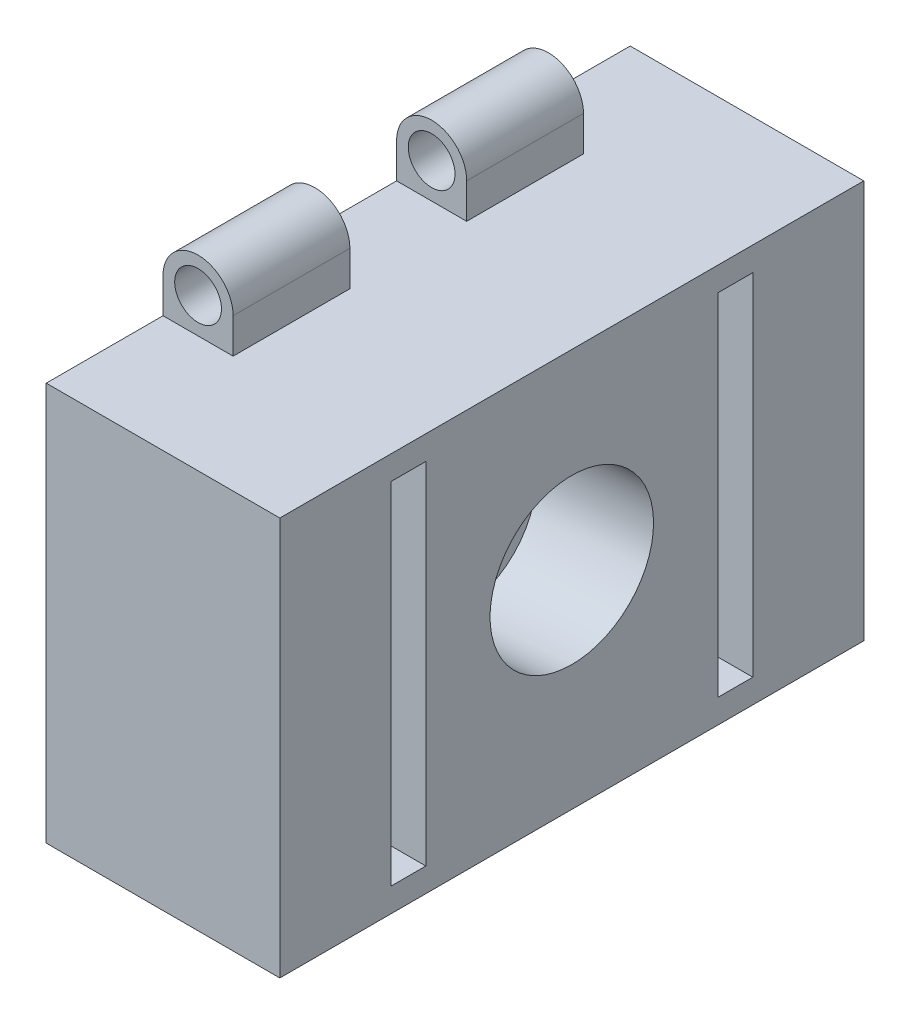
from build123d import *

# Parameters (mm, degrees)
SKETCH1_W                      = 50
SKETCH1_H                      = 34.11
BOSS_EXTRUDE1_DEPTH            = 20
SKETCH3_R                      = 2
BOSS_EXTRUDE2_DEPTH            = 10
LPATTERN1_COUNT                = 2
LPATTERN1_PITCH                = 20
MIRROR1_COPY_1_SKETCH_R        = 2
MIRROR1_COPY_1_DEPTH           = 10
SKETCH5_R                      = 7
CUT_EXTRUDE1_DEPTH             = 10
CUT_EXTRUDE1_DIRECTION_2_REACH = 3.559
SKETCH6_W                      = 3
SKETCH6_H                      = 30
CUT_EXTRUDE2_DEPTH             = 10


with BuildPart() as part:
    # Sketch1 → Boss-Extrude1 (new body)
    with BuildSketch(Plane(origin=(0, 0, 0), x_dir=(0, 0, -1), z_dir=(1, 0, 0))):
        with Locations((25, 17.055)):
            Rectangle(SKETCH1_W, SKETCH1_H)
    extrude(amount=BOSS_EXTRUDE1_DEPTH)

    # Sketch3 → Boss-Extrude2 (add)
    with BuildSketch(Plane.XY.offset(-10)):
        with BuildLine():
            Line((0, 34.11), (0, 37.11))
            ThreePointArc((0, 37.11), (3, 40.11), (6, 37.11))
            Line((6, 37.11), (6, 34.11))
            Line((6, 34.11), (3, 34.11))
            Line((3, 34.11), (0, 34.11))
        make_face()
        with Locations((3, 37.11)):
            Circle(SKETCH3_R, mode=Mode.SUBTRACT)
    boss_extrude2 = extrude(amount=-BOSS_EXTRUDE2_DEPTH)

    # LPattern1: Boss-Extrude2 ×2
    with Locations(*[(0, 0, -i * LPATTERN1_PITCH) for i in range(1, LPATTERN1_COUNT)]):
        add(boss_extrude2)

    # Mirror1: Boss-Extrude2 across plane
    add(boss_extrude2.mirror(Plane.ZX.offset(17.055)))

    # Mirror1 copy 1 sketch → Mirror1 copy 1 (add)
    with BuildSketch(Plane(origin=(0, 34.11, -30), x_dir=(1, 0, 0), z_dir=(0, 0, 1))):
        with BuildLine():
            Line((0, -34.11), (0, -37.11))
            ThreePointArc((0, -37.11), (3, -40.11), (6, -37.11))
            Line((6, -37.11), (6, -34.11))
            Line((6, -34.11), (3, -34.11))
            Line((3, -34.11), (0, -34.11))
        make_face()
        with Locations((3, -37.11)):
            Circle(MIRROR1_COPY_1_SKETCH_R, mode=Mode.SUBTRACT)
    extrude(amount=-MIRROR1_COPY_1_DEPTH)

    # Sketch5 → Cut-Extrude1 (cut)
    with BuildSketch(Plane(origin=(20, 17.754268119, -25), x_dir=(0, 0, -1), z_dir=(0.99756405, 0.069756474, 0))):
        Circle(SKETCH5_R)
    extrude(amount=-CUT_EXTRUDE1_DEPTH, mode=Mode.SUBTRACT)

    # Sketch5 → Cut-Extrude1 direction 2 (cut, up to next)
    with BuildSketch(Plane(origin=(20, 17.754268119, -25), x_dir=(0, 0, -1), z_dir=(0.99756405, 0.069756474, 0)), mode=Mode.PRIVATE) as cut_extrude1_direction_2_sk1:
        Circle(SKETCH5_R)
    cut_extrude1_direction_2_tool1 = extrude(cut_extrude1_direction_2_sk1.sketch, amount=CUT_EXTRUDE1_DIRECTION_2_REACH, mode=Mode.PRIVATE) & part.part
    add(cut_extrude1_direction_2_tool1.solids().sort_by_distance((20, 17.754268, -25))[0], mode=Mode.SUBTRACT)

    # Sketch6 → Cut-Extrude2 (cut)
    with BuildSketch(Plane(origin=(20, 0, 0), x_dir=(0, 0, -1), z_dir=(1, 0, 0))):
        with Locations((11, 17.055)):
            Rectangle(SKETCH6_W, SKETCH6_H)
        with Locations((39, 17.055)):
            Rectangle(SKETCH6_W, SKETCH6_H)
    extrude(amount=-CUT_EXTRUDE2_DEPTH, mode=Mode.SUBTRACT)


solid = part.part
